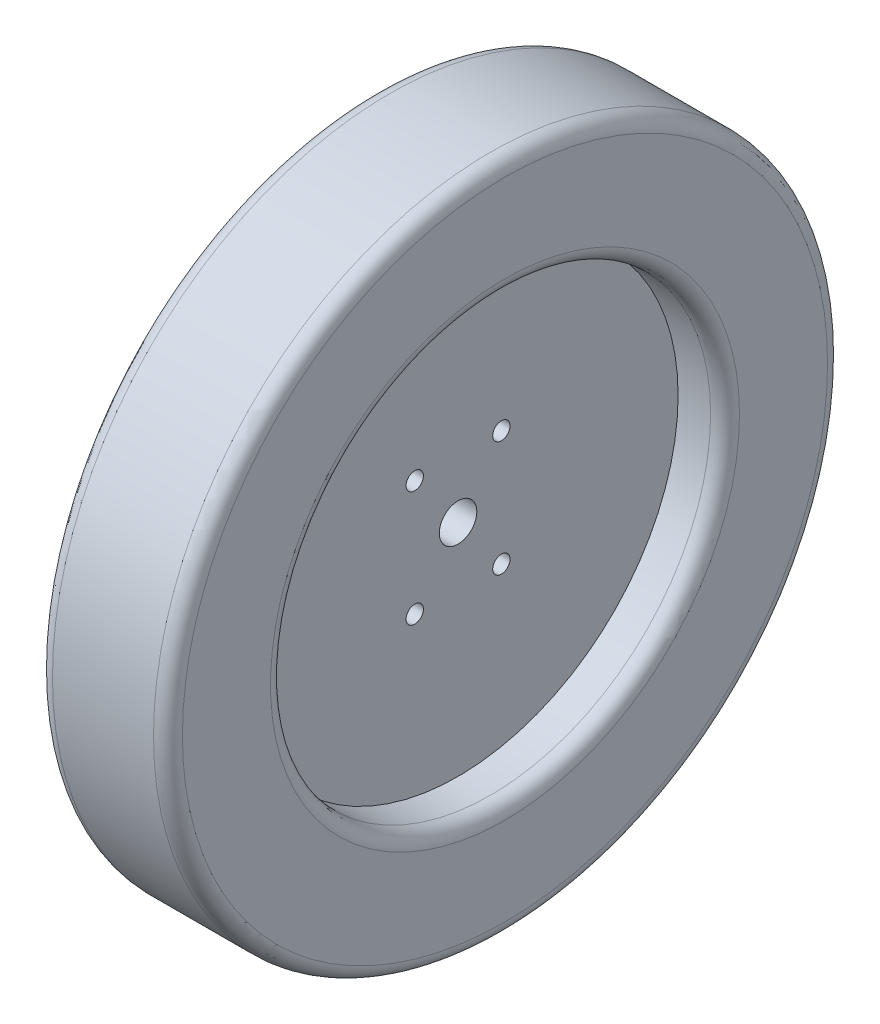
from build123d import *

# Parameters (mm, degrees)
SKETCH1_R               = 233.4
SKETCH1_R_2             = 152.4
BOSS_EXTRUDE1_DEPTH     = 45
SKETCH2_R               = 152.4
BOSS_EXTRUDE2_DEPTH     = 12.5
FILLET2_R               = 10
FILLET3_R               = 10
FILLET4_R               = 10
SKETCH3_R               = 13
SKETCH3_R_2             = 6
CUT_EXTRUDE2_DEPTH      = 46
CUT_EXTRUDE2_DEPTH_BACK = 46


with BuildPart() as part:
    # Sketch1 → Boss-Extrude1 (new body, symmetric)
    with BuildSketch(Plane(origin=(0, 0, 0), x_dir=(0, 0, -1), z_dir=(1, 0, 0))):
        Circle(SKETCH1_R)
        Circle(SKETCH1_R_2, mode=Mode.SUBTRACT)
    extrude(amount=BOSS_EXTRUDE1_DEPTH, both=True)

    # Sketch2 → Boss-Extrude2 (add, symmetric)
    with BuildSketch(Plane(origin=(0, 0, 0), x_dir=(0, 0, -1), z_dir=(1, 0, 0))):
        Circle(SKETCH2_R)
    extrude(amount=BOSS_EXTRUDE2_DEPTH, both=True)

    # Fillet2
    fillet2_edges = [part.edges().sort_by_distance(p)[0] for p in [
        (45, 0, 233.4),
    ]]
    fillet(fillet2_edges, radius=FILLET2_R)

    # Fillet3
    fillet3_edges = [part.edges().sort_by_distance(p)[0] for p in [
        (-45, 0, 233.4),
        (45, 0, 152.4),
    ]]
    fillet(fillet3_edges, radius=FILLET3_R)

    # Fillet4
    fillet4_edges = [part.edges().sort_by_distance(p)[0] for p in [
        (-45, 0, 152.4),
    ]]
    fillet(fillet4_edges, radius=FILLET4_R)

    # Sketch3 → Cut-Extrude2 (cut, two sides)
    with BuildSketch(Plane(origin=(0, 0, 0), x_dir=(0, 0, -1), z_dir=(1, 0, 0))) as cut_extrude2_sk:
        Circle(SKETCH3_R)
        with Locations((30, 40)):
            Circle(SKETCH3_R_2)
        with Locations((-30, 40)):
            Circle(SKETCH3_R_2)
        with Locations((-30, -40)):
            Circle(SKETCH3_R_2)
        with Locations((30, -40)):
            Circle(SKETCH3_R_2)
    extrude(amount=CUT_EXTRUDE2_DEPTH, mode=Mode.SUBTRACT)
    extrude(cut_extrude2_sk.sketch, amount=-CUT_EXTRUDE2_DEPTH_BACK, mode=Mode.SUBTRACT)


solid = part.part
